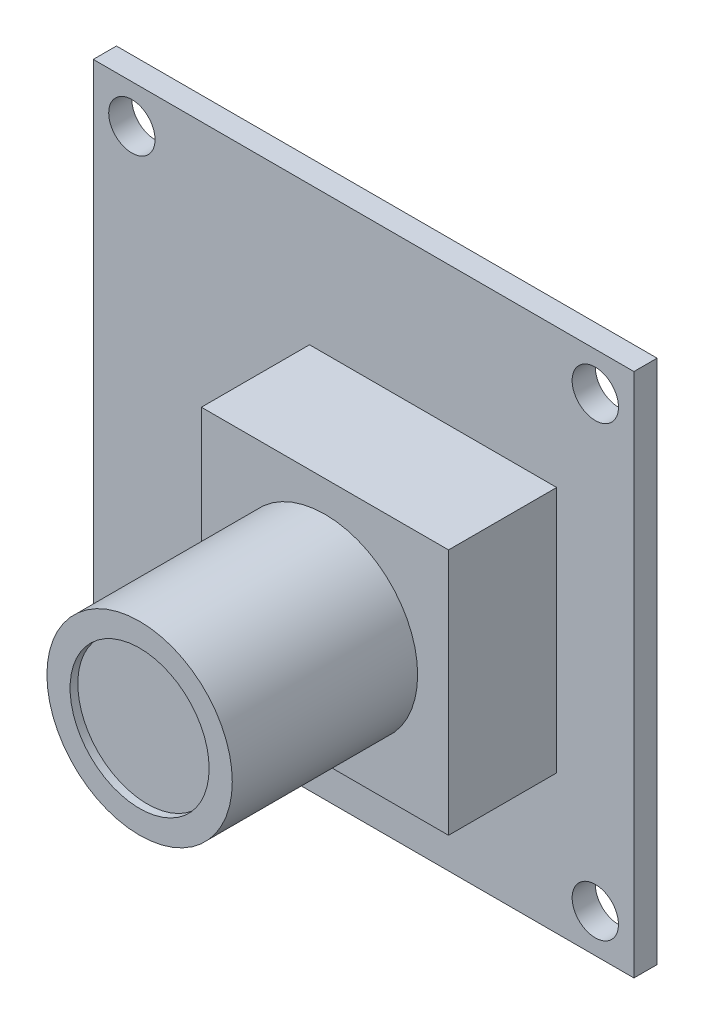
from build123d import *

# Parameters (mm, degrees)
SKETCH1_W           = 35
SKETCH1_H           = 34
BOSS_EXTRUDE1_DEPTH = 1.5
CUT_EXTRUDE1_REACH  = 3.5
SKETCH2_R           = 1.5
SKETCH3_W           = 16
SKETCH3_H           = 16
BOSS_EXTRUDE3_DEPTH = 7
SKETCH4_R           = 6
BOSS_EXTRUDE4_DEPTH = 12
SKETCH7_R           = 4.5
CUT_EXTRUDE2_DEPTH  = 0.5
SKETCH8_W           = 4
SKETCH8_H           = 20
BOSS_EXTRUDE5_DEPTH = 6


with BuildPart() as part:
    # Sketch1 → Boss-Extrude1 (new body)
    with BuildSketch(Plane.XY):
        Rectangle(SKETCH1_W, SKETCH1_H)
    extrude(amount=-BOSS_EXTRUDE1_DEPTH)

    # Sketch2 → Cut-Extrude1 (cut, up to next)
    with BuildSketch(Plane.XY, mode=Mode.PRIVATE) as cut_extrude1_sk1:
        with Locations((-15, -14.5)):
            Circle(SKETCH2_R)
    cut_extrude1_tool1 = extrude(cut_extrude1_sk1.sketch, amount=-CUT_EXTRUDE1_REACH, mode=Mode.PRIVATE) & part.part
    add(cut_extrude1_tool1.solids().sort_by_distance((-15, -14.5, 0))[0], mode=Mode.SUBTRACT)
    # Sketch2 → Cut-Extrude1 (cut, up to next)
    with BuildSketch(Plane.XY, mode=Mode.PRIVATE) as cut_extrude1_sk2:
        with Locations((15, -14.5)):
            Circle(SKETCH2_R)
    cut_extrude1_tool2 = extrude(cut_extrude1_sk2.sketch, amount=-CUT_EXTRUDE1_REACH, mode=Mode.PRIVATE) & part.part
    add(cut_extrude1_tool2.solids().sort_by_distance((15, -14.5, 0))[0], mode=Mode.SUBTRACT)
    # Sketch2 → Cut-Extrude1 (cut, up to next)
    with BuildSketch(Plane.XY, mode=Mode.PRIVATE) as cut_extrude1_sk3:
        with Locations((15, 14.5)):
            Circle(SKETCH2_R)
    cut_extrude1_tool3 = extrude(cut_extrude1_sk3.sketch, amount=-CUT_EXTRUDE1_REACH, mode=Mode.PRIVATE) & part.part
    add(cut_extrude1_tool3.solids().sort_by_distance((15, 14.5, 0))[0], mode=Mode.SUBTRACT)
    # Sketch2 → Cut-Extrude1 (cut, up to next)
    with BuildSketch(Plane.XY, mode=Mode.PRIVATE) as cut_extrude1_sk4:
        with Locations((-15, 14.5)):
            Circle(SKETCH2_R)
    cut_extrude1_tool4 = extrude(cut_extrude1_sk4.sketch, amount=-CUT_EXTRUDE1_REACH, mode=Mode.PRIVATE) & part.part
    add(cut_extrude1_tool4.solids().sort_by_distance((-15, 14.5, 0))[0], mode=Mode.SUBTRACT)

    # Sketch3 → Boss-Extrude3 (add)
    with BuildSketch(Plane.XY):
        with Locations((4.5, 0)):
            Rectangle(SKETCH3_W, SKETCH3_H)
    extrude(amount=BOSS_EXTRUDE3_DEPTH)

    # Sketch4 → Boss-Extrude4 (add)
    with BuildSketch(Plane.XY.offset(7)):
        with Locations((4.5, 0)):
            Circle(SKETCH4_R)
    extrude(amount=BOSS_EXTRUDE4_DEPTH)

    # Sketch7 → Cut-Extrude2 (cut)
    with BuildSketch(Plane.XY.offset(19)):
        with Locations((4.5, 0)):
            Circle(SKETCH7_R)
    extrude(amount=-CUT_EXTRUDE2_DEPTH, mode=Mode.SUBTRACT)

    # Sketch8 → Boss-Extrude5 (add)
    with BuildSketch(Plane(origin=(0, 0, -1.5), x_dir=(-1, 0, 0), z_dir=(0, 0, -1))):
        with Locations((10, 0)):
            Rectangle(SKETCH8_W, SKETCH8_H)
    extrude(amount=BOSS_EXTRUDE5_DEPTH)


solid = part.part
